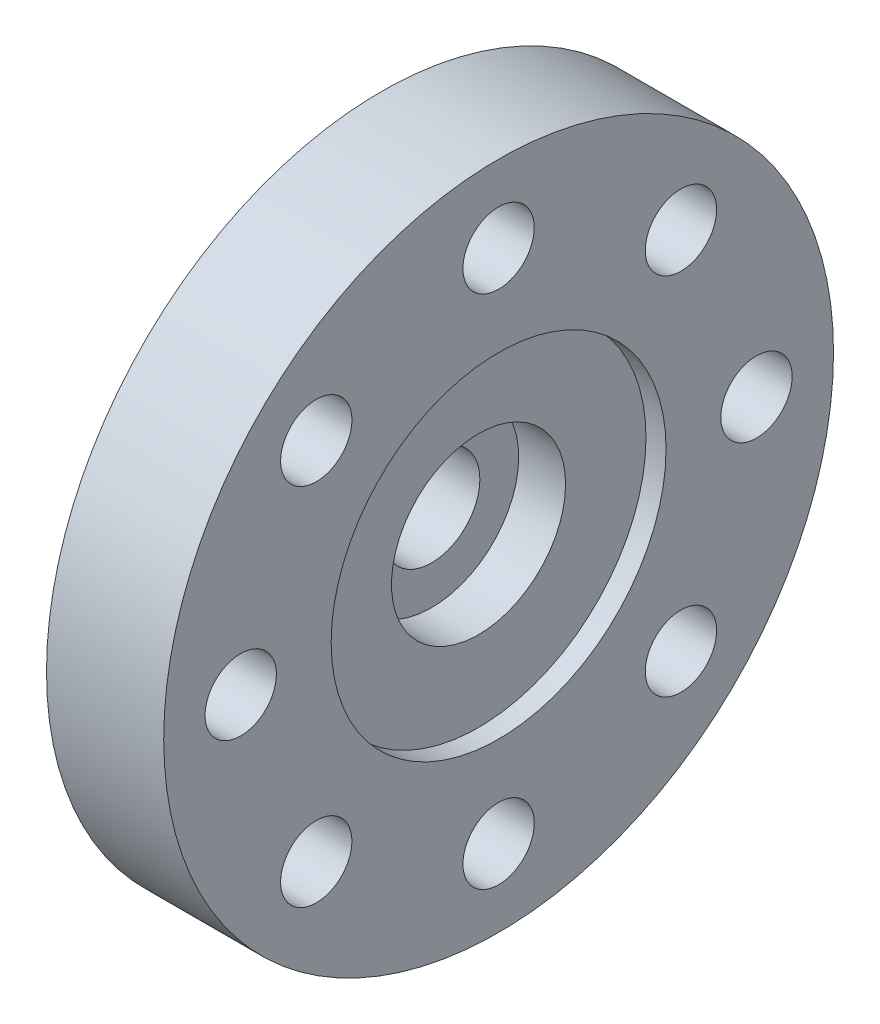
from build123d import *

# Parameters (mm, degrees)
SKETCH1_R           = 12.7
SKETCH1_R_2         = 1.35255
BOSS_EXTRUDE1_DEPTH = 4.445
SKETCH2_R           = 6.35
CUT_EXTRUDE1_DEPTH  = 0.762
SKETCH3_R           = 3.302
CUT_EXTRUDE2_DEPTH  = 1.778
SKETCH4_R           = 1.8288
CUT_EXTRUDE3_DEPTH  = 2.905


with BuildPart() as part:
    # Sketch1 → Boss-Extrude1 (new body)
    with BuildSketch(Plane(origin=(0, 0, 0), x_dir=(0, 0, -1), z_dir=(1, 0, 0))):
        Circle(SKETCH1_R)
        with Locations((0, 9.779)):
            Circle(SKETCH1_R_2, mode=Mode.SUBTRACT)
        with Locations((6.914797213, 6.914797213)):
            Circle(SKETCH1_R_2, mode=Mode.SUBTRACT)
        with Locations((9.779, 0)):
            Circle(SKETCH1_R_2, mode=Mode.SUBTRACT)
        with Locations((6.914797213, -6.914797213)):
            Circle(SKETCH1_R_2, mode=Mode.SUBTRACT)
        with Locations((0, -9.779)):
            Circle(SKETCH1_R_2, mode=Mode.SUBTRACT)
        with Locations((-6.914797213, -6.914797213)):
            Circle(SKETCH1_R_2, mode=Mode.SUBTRACT)
        with Locations((-9.779, 0)):
            Circle(SKETCH1_R_2, mode=Mode.SUBTRACT)
        with Locations((-6.914797213, 6.914797213)):
            Circle(SKETCH1_R_2, mode=Mode.SUBTRACT)
    extrude(amount=BOSS_EXTRUDE1_DEPTH)

    # Sketch2 → Cut-Extrude1 (cut)
    with BuildSketch(Plane(origin=(4.445, 0, 0), x_dir=(0, 0, -1), z_dir=(1, 0, 0))):
        Circle(SKETCH2_R)
    extrude(amount=-CUT_EXTRUDE1_DEPTH, mode=Mode.SUBTRACT)

    # Sketch3 → Cut-Extrude2 (cut)
    with BuildSketch(Plane(origin=(3.683, 0, 0), x_dir=(0, 0, -1), z_dir=(1, 0, 0))):
        Circle(SKETCH3_R)
    extrude(amount=-CUT_EXTRUDE2_DEPTH, mode=Mode.SUBTRACT)

    # Sketch4 → Cut-Extrude3 (cut, through all)
    with BuildSketch(Plane(origin=(1.905, 0, 0), x_dir=(0, 0, -1), z_dir=(1, 0, 0))):
        Circle(SKETCH4_R)
    extrude(amount=-CUT_EXTRUDE3_DEPTH, mode=Mode.SUBTRACT)


solid = part.part
